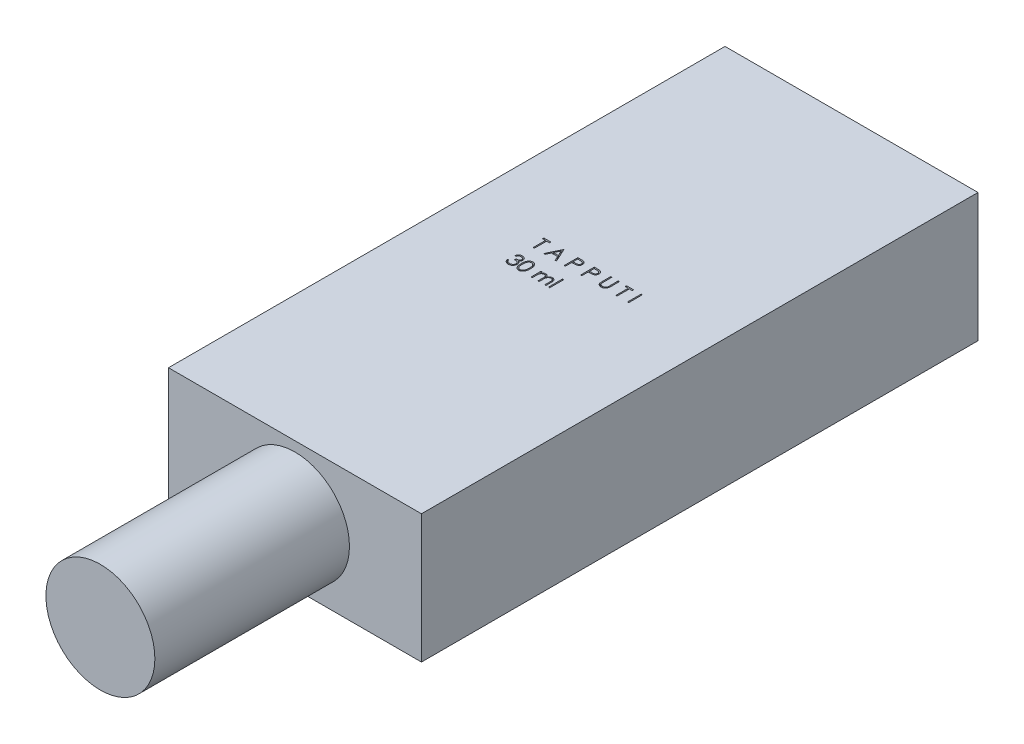
from build123d import *

# Parameters (mm, degrees)
SKETCH1_W           = 65
SKETCH1_H           = 143
BOSS_EXTRUDE1_DEPTH = 33
SKETCH2_W           = 0.314102564
SKETCH2_H           = 3.5
SKETCH2_H_2         = 3.58974359
CUT_EXTRUDE1_DEPTH  = 10
SKETCH4_R           = 14
BOSS_EXTRUDE2_DEPTH = 50


with BuildPart() as part:
    # Sketch1 → Boss-Extrude1 (new body)
    with BuildSketch(Plane(origin=(0, 0, 0), x_dir=(1, 0, 0), z_dir=(0, 1, 0))):
        Rectangle(SKETCH1_W, SKETCH1_H)
    extrude(amount=-BOSS_EXTRUDE1_DEPTH)

    # Sketch2 → Cut-Extrude1 (cut)
    with BuildSketch(Plane(origin=(0, 0, 0), x_dir=(1, 0, 0), z_dir=(0, 1, 0))):
        Polygon((-13.158043285, 5.236726447), (-13.158043285, 5.595700806), (-11.318299695, 5.595700806), (-11.318299695, 5.236726447), (-12.081120208, 5.236726447), (-12.081120208, 2.095700806), (-12.395222772, 2.095700806), (-12.395222772, 5.236726447), align=None)
        Polygon((-7.997786875, 5.595700806), (-6.382402259, 2.095700806), (-6.723848574, 2.095700806), (-7.241276458, 3.217495678), (-8.82791508, 3.217495678), (-9.360066522, 2.095700806), (-9.70291508, 2.095700806), (-8.04265867, 5.595700806), align=None)
        Polygon((-8.023728381, 4.9135093), (-8.657542484, 3.576470037), (-7.406741202, 3.576470037), align=None, mode=Mode.SUBTRACT)
        with BuildLine():
            Line((-4.408043285, 5.595700806), (-3.721645048, 5.595700806))
            add(Edge.make_bspline(
                [(-3.721645048, 5.595700806), (-3.674434142, 5.59564891), (-3.583975949, 5.595549475), (-3.454260893, 5.592534729), (-3.336451162, 5.588508037), (-3.230800781, 5.582926143), (-3.136984683, 5.576329553), (-3.055427383, 5.567077514), (-2.985487827, 5.557417218), (-2.943581377, 5.547595812), (-2.924469567, 5.543116672)],
                knots=[0, 0, 0, 0, 0.000141628, 0.000271366, 0.00038923, 0.000495248, 0.00058876, 0.000671296, 0.000741499, 0.00080036, 0.00080036, 0.00080036, 0.00080036], degree=3))
            add(Edge.make_bspline(
                [(-2.924469567, 5.543116672), (-2.900276033, 5.536494722), (-2.852459056, 5.52340686), (-2.783558013, 5.497193137), (-2.718004168, 5.466110972), (-2.655572609, 5.430687032), (-2.597030526, 5.389401468), (-2.541504485, 5.34392785), (-2.489484505, 5.293216281), (-2.441263113, 5.237835541), (-2.396978315, 5.178715331), (-2.358848633, 5.114973102), (-2.326921406, 5.047681798), (-2.299538134, 4.976888227), (-2.27982968, 4.901997903), (-2.26498278, 4.823531191), (-2.255559152, 4.741496501), (-2.25465659, 4.685436633), (-2.254197131, 4.656898723)],
                knots=[0, 0, 0, 0, 7.5216e-05, 0.00014866, 0.000220794, 0.000292713, 0.000363707, 0.000435434, 0.000507823, 0.000581364, 0.000655543, 0.000729131, 0.000803767, 0.000878771, 0.000956497, 0.001035702, 0.001118238, 0.001203821, 0.001203821, 0.001203821, 0.001203821], degree=3))
            add(Edge.make_bspline(
                [(-2.254197131, 4.656898723), (-2.254618556, 4.628120946), (-2.255443102, 4.571815282), (-2.265339387, 4.489442494), (-2.278669579, 4.410724104), (-2.299166631, 4.335834653), (-2.326012304, 4.265218883), (-2.357504357, 4.197797651), (-2.395487887, 4.134717979), (-2.439132717, 4.075750862), (-2.487684312, 4.020840949), (-2.54093725, 3.970386155), (-2.598676542, 3.924681816), (-2.66071869, 3.883625473), (-2.727668539, 3.848169193), (-2.798510693, 3.816411888), (-2.873860909, 3.789740828), (-2.926003423, 3.775710766), (-2.952514439, 3.768577409)],
                knots=[0, 0, 0, 0, 8.6284e-05, 0.00016882, 0.000248587, 0.000325638, 0.000401297, 0.000474998, 0.000548586, 0.000621785, 0.0006948, 0.0007682, 0.000841564, 0.000915458, 0.000991056, 0.00106858, 0.00114819, 0.001230532, 0.001230532, 0.001230532, 0.001230532], degree=3))
            add(Edge.make_bspline(
                [(-2.952514439, 3.768577409), (-2.974441773, 3.763914428), (-3.0224968, 3.753695234), (-3.101639522, 3.742286777), (-3.193784908, 3.732549176), (-3.298807188, 3.725248039), (-3.416612093, 3.71899767), (-3.547263351, 3.714029576), (-3.691017428, 3.711299722), (-3.791288672, 3.71115893), (-3.84364024, 3.711085422)],
                knots=[0, 0, 0, 0, 6.7238e-05, 0.000147357, 0.000239727, 0.000345177, 0.000463135, 0.000593636, 0.000737393, 0.000894446, 0.000894446, 0.000894446, 0.000894446], degree=3))
            Line((-3.84364024, 3.711085422), (-4.093940721, 3.711085422))
            Line((-4.093940721, 3.711085422), (-4.093940721, 2.095700806))
            Line((-4.093940721, 2.095700806), (-4.408043285, 2.095700806))
            Line((-4.408043285, 2.095700806), (-4.408043285, 5.595700806))
        make_face()
        with BuildLine():
            Line((-4.093940721, 5.236726447), (-4.093940721, 4.070059781))
            Line((-4.093940721, 4.070059781), (-3.481160272, 4.062347441))
            add(Edge.make_bspline(
                [(-3.481160272, 4.062347441), (-3.451240346, 4.062331977), (-3.393480546, 4.062302125), (-3.310044323, 4.066287349), (-3.232635036, 4.070887881), (-3.161490461, 4.077623805), (-3.096578526, 4.087145062), (-3.037790997, 4.0967568), (-2.985583714, 4.110662163), (-2.924484513, 4.129385232), (-2.856401165, 4.161317848), (-2.782333617, 4.207667738), (-2.71956303, 4.266748446), (-2.665244733, 4.333176277), (-2.622138856, 4.407075407), (-2.590582863, 4.486144343), (-2.572041706, 4.569572193), (-2.569555512, 4.626660332), (-2.568299695, 4.655496479)],
                knots=[0, 0, 0, 0, 8.9746e-05, 0.000173253, 0.000250533, 0.00032239, 0.000387534, 0.00044736, 0.000500926, 0.000549486, 0.000638903, 0.000725641, 0.000810488, 0.000896226, 0.000982324, 0.00106604, 0.001150757, 0.001237226, 0.001237226, 0.001237226, 0.001237226], degree=3))
            add(Edge.make_bspline(
                [(-2.568299695, 4.655496479), (-2.569562342, 4.683634993), (-2.572072327, 4.739570875), (-2.59072819, 4.821549636), (-2.622077504, 4.89978534), (-2.665534098, 4.972758425), (-2.718275228, 5.038947229), (-2.779574571, 5.096444356), (-2.849287833, 5.142666059), (-2.914136064, 5.172499341), (-2.97173725, 5.190714616), (-3.02176921, 5.203459457), (-3.078259884, 5.213635063), (-3.141227664, 5.221874566), (-3.210184498, 5.228928027), (-3.285722812, 5.233714004), (-3.367556456, 5.23651546), (-3.424367027, 5.236654416), (-3.453816522, 5.236726447)],
                knots=[0, 0, 0, 0, 8.4371e-05, 0.000167719, 0.000250783, 0.000336277, 0.000421575, 0.000503926, 0.000587348, 0.000671427, 0.000717102, 0.000768457, 0.000826213, 0.000889178, 0.000958942, 0.001034123, 0.001116202, 0.001204546, 0.001204546, 0.001204546, 0.001204546], degree=3))
            Line((-3.453816522, 5.236726447), (-4.093940721, 5.236726447))
        make_face(mode=Mode.SUBTRACT)
        with BuildLine():
            Line((-0.190094567, 5.595700806), (0.49630367, 5.595700806))
            add(Edge.make_bspline(
                [(0.49630367, 5.595700806), (0.543514576, 5.59564891), (0.633972769, 5.595549475), (0.763687825, 5.592534729), (0.881497556, 5.588508037), (0.987147937, 5.582926143), (1.080964035, 5.576329553), (1.162521335, 5.567077514), (1.232460891, 5.557417218), (1.274367341, 5.547595812), (1.293479151, 5.543116672)],
                knots=[0, 0, 0, 0, 0.000141628, 0.000271366, 0.00038923, 0.000495248, 0.00058876, 0.000671296, 0.000741499, 0.00080036, 0.00080036, 0.00080036, 0.00080036], degree=3))
            add(Edge.make_bspline(
                [(1.293479151, 5.543116672), (1.317672685, 5.536494722), (1.365489662, 5.52340686), (1.434390705, 5.497193137), (1.49994455, 5.466110972), (1.562376109, 5.430687032), (1.620918192, 5.389401468), (1.676444233, 5.34392785), (1.728464213, 5.293216281), (1.776685605, 5.237835541), (1.820970403, 5.178715331), (1.859100085, 5.114973102), (1.891027312, 5.047681798), (1.918410584, 4.976888227), (1.938119038, 4.901997903), (1.952965938, 4.823531191), (1.962389566, 4.741496501), (1.963292127, 4.685436633), (1.963751587, 4.656898723)],
                knots=[0, 0, 0, 0, 7.5216e-05, 0.00014866, 0.000220794, 0.000292713, 0.000363707, 0.000435434, 0.000507823, 0.000581364, 0.000655543, 0.000729131, 0.000803767, 0.000878771, 0.000956497, 0.001035702, 0.001118238, 0.001203821, 0.001203821, 0.001203821, 0.001203821], degree=3))
            add(Edge.make_bspline(
                [(1.963751587, 4.656898723), (1.963330162, 4.628120946), (1.962505616, 4.571815282), (1.952609331, 4.489442494), (1.939279139, 4.410724104), (1.918782087, 4.335834653), (1.891936414, 4.265218883), (1.860444361, 4.197797651), (1.82246083, 4.134717979), (1.778816001, 4.075750862), (1.730264406, 4.020840949), (1.677011468, 3.970386155), (1.619272176, 3.924681816), (1.557230028, 3.883625473), (1.490280179, 3.848169193), (1.419438025, 3.816411888), (1.344087809, 3.789740828), (1.291945295, 3.775710766), (1.265434279, 3.768577409)],
                knots=[0, 0, 0, 0, 8.6284e-05, 0.00016882, 0.000248587, 0.000325638, 0.000401297, 0.000474998, 0.000548586, 0.000621785, 0.0006948, 0.0007682, 0.000841564, 0.000915458, 0.000991056, 0.00106858, 0.00114819, 0.001230532, 0.001230532, 0.001230532, 0.001230532], degree=3))
            add(Edge.make_bspline(
                [(1.265434279, 3.768577409), (1.243506945, 3.763914428), (1.195451918, 3.753695234), (1.116309196, 3.742286777), (1.02416381, 3.732549176), (0.91914153, 3.725248039), (0.801336625, 3.71899767), (0.670685367, 3.714029576), (0.52693129, 3.711299722), (0.426660046, 3.71115893), (0.374308478, 3.711085422)],
                knots=[0, 0, 0, 0, 6.7238e-05, 0.000147357, 0.000239727, 0.000345177, 0.000463135, 0.000593636, 0.000737393, 0.000894446, 0.000894446, 0.000894446, 0.000894446], degree=3))
            Line((0.374308478, 3.711085422), (0.124007997, 3.711085422))
            Line((0.124007997, 3.711085422), (0.124007997, 2.095700806))
            Line((0.124007997, 2.095700806), (-0.190094567, 2.095700806))
            Line((-0.190094567, 2.095700806), (-0.190094567, 5.595700806))
        make_face()
        with BuildLine():
            Line((0.124007997, 5.236726447), (0.124007997, 4.070059781))
            Line((0.124007997, 4.070059781), (0.736788446, 4.062347441))
            add(Edge.make_bspline(
                [(0.736788446, 4.062347441), (0.766708372, 4.062331977), (0.824468171, 4.062302125), (0.907904395, 4.066287349), (0.985313682, 4.070887881), (1.056458257, 4.077623805), (1.121370192, 4.087145062), (1.180157721, 4.0967568), (1.232365004, 4.110662163), (1.293464205, 4.129385232), (1.361547553, 4.161317848), (1.435615101, 4.207667738), (1.498385688, 4.266748446), (1.552703984, 4.333176277), (1.595809862, 4.407075407), (1.627365855, 4.486144343), (1.645907012, 4.569572193), (1.648393206, 4.626660332), (1.649649023, 4.655496479)],
                knots=[0, 0, 0, 0, 8.9746e-05, 0.000173253, 0.000250533, 0.00032239, 0.000387534, 0.00044736, 0.000500926, 0.000549486, 0.000638903, 0.000725641, 0.000810488, 0.000896226, 0.000982324, 0.00106604, 0.001150757, 0.001237226, 0.001237226, 0.001237226, 0.001237226], degree=3))
            add(Edge.make_bspline(
                [(1.649649023, 4.655496479), (1.648386376, 4.683634993), (1.645876391, 4.739570875), (1.627220528, 4.821549636), (1.595871214, 4.89978534), (1.55241462, 4.972758425), (1.49967349, 5.038947229), (1.438374147, 5.096444356), (1.368660885, 5.142666059), (1.303812654, 5.172499341), (1.246211468, 5.190714616), (1.196179508, 5.203459457), (1.139688834, 5.213635063), (1.076721054, 5.221874566), (1.00776422, 5.228928027), (0.932225906, 5.233714004), (0.850392262, 5.23651546), (0.793581691, 5.236654416), (0.764132196, 5.236726447)],
                knots=[0, 0, 0, 0, 8.4371e-05, 0.000167719, 0.000250783, 0.000336277, 0.000421575, 0.000503926, 0.000587348, 0.000671427, 0.000717102, 0.000768457, 0.000826213, 0.000889178, 0.000958942, 0.001034123, 0.001116202, 0.001204546, 0.001204546, 0.001204546, 0.001204546], degree=3))
            Line((0.764132196, 5.236726447), (0.124007997, 5.236726447))
        make_face(mode=Mode.SUBTRACT)
        with BuildLine():
            Line((4.027854151, 5.595700806), (4.341956715, 5.595700806))
            Line((4.341956715, 5.595700806), (4.341956715, 3.498645518))
            add(Edge.make_bspline(
                [(4.341956715, 3.498645518), (4.341909971, 3.468964782), (4.341821266, 3.412640471), (4.34241378, 3.332472171), (4.344073149, 3.261199712), (4.345119308, 3.198548364), (4.347446642, 3.144805617), (4.349344689, 3.099680306), (4.351785245, 3.063386103), (4.354718363, 3.042205177), (4.355979151, 3.033100646)],
                knots=[0, 0, 0, 0, 8.9042e-05, 0.000168973, 0.000240502, 0.000302917, 0.000356945, 0.000401866, 0.000438432, 0.000465999, 0.000465999, 0.000465999, 0.000465999], degree=3))
            add(Edge.make_bspline(
                [(4.355979151, 3.033100646), (4.36115661, 3.000253883), (4.371219796, 2.936411154), (4.396866174, 2.845502872), (4.432683675, 2.763571413), (4.475126717, 2.688060122), (4.531059329, 2.621070762), (4.598062864, 2.55935911), (4.679240633, 2.505387305), (4.769501238, 2.456036493), (4.866786476, 2.416371411), (4.966197742, 2.386378046), (5.066240721, 2.368099147), (5.133216886, 2.365982608), (5.166475946, 2.364931576)],
                knots=[0, 0, 0, 0, 9.971e-05, 0.000193801, 0.000282365, 0.000367504, 0.000452699, 0.000543015, 0.000639862, 0.000744331, 0.000851226, 0.000954377, 0.001055468, 0.001155185, 0.001155185, 0.001155185, 0.001155185], degree=3))
            add(Edge.make_bspline(
                [(5.166475946, 2.364931576), (5.195029686, 2.366005426), (5.251972248, 2.368146924), (5.336578679, 2.381408355), (5.418978787, 2.405308921), (5.499579467, 2.436148679), (5.575130452, 2.47689627), (5.645673894, 2.52396711), (5.708637828, 2.579177986), (5.766095826, 2.64027833), (5.816130762, 2.70921813), (5.859501903, 2.784496268), (5.895027833, 2.867245615), (5.912571358, 2.925400038), (5.921584119, 2.955276127)],
                knots=[0, 0, 0, 0, 8.5678e-05, 0.00017086, 0.000256092, 0.000342674, 0.000429242, 0.000513055, 0.000596556, 0.000679898, 0.000764179, 0.00085149, 0.000940054, 0.001033621, 0.001033621, 0.001033621, 0.001033621], degree=3))
            add(Edge.make_bspline(
                [(5.921584119, 2.955276127), (5.924584244, 2.967624701), (5.931269732, 2.995142301), (5.937516777, 3.041663592), (5.944023303, 3.096552956), (5.948537873, 3.160204769), (5.952939093, 3.232405741), (5.955572166, 3.313531999), (5.956789199, 3.40328896), (5.957151879, 3.465926121), (5.95734133, 3.498645518)],
                knots=[0, 0, 0, 0, 3.81e-05, 8.4902e-05, 0.000140649, 0.000203941, 0.000276279, 0.000357657, 0.000447412, 0.000545571, 0.000545571, 0.000545571, 0.000545571], degree=3))
            Line((5.95734133, 3.498645518), (5.95734133, 5.595700806))
            Line((5.95734133, 5.595700806), (6.271443894, 5.595700806))
            Line((6.271443894, 5.595700806), (6.271443894, 3.481818595))
            add(Edge.make_bspline(
                [(6.271443894, 3.481818595), (6.271189774, 3.443720216), (6.270693843, 3.369368913), (6.266393266, 3.260417554), (6.259536266, 3.157064573), (6.249848178, 3.059296076), (6.237011175, 2.967461917), (6.222735955, 2.880757149), (6.204556422, 2.799804156), (6.18332302, 2.723971738), (6.159049472, 2.651786225), (6.127608324, 2.58327761), (6.092183824, 2.516363211), (6.050169171, 2.452055102), (6.002957789, 2.390068549), (5.949506108, 2.330779474), (5.891581947, 2.273240427), (5.828222387, 2.218927361), (5.760471862, 2.169118684), (5.688531904, 2.125320913), (5.612955135, 2.088297296), (5.533938009, 2.057821371), (5.451446806, 2.034906772), (5.365479446, 2.017831616), (5.275840253, 2.008129319), (5.214875596, 2.006687389), (5.184003991, 2.005957217)],
                knots=[0, 0, 0, 0, 0.000114291, 0.000223047, 0.000327049, 0.000424998, 0.000517708, 0.000605194, 0.000688542, 0.000766455, 0.0008414, 0.000916717, 0.000992315, 0.001068354, 0.001146882, 0.001225836, 0.001307639, 0.001391671, 0.001475952, 0.001559641, 0.001643989, 0.001728103, 0.001813335, 0.001900511, 0.00199079, 0.002083404, 0.002083404, 0.002083404, 0.002083404], degree=3))
            add(Edge.make_bspline(
                [(5.184003991, 2.005957217), (5.150334888, 2.006741982), (5.084276229, 2.008281689), (4.986938162, 2.017104439), (4.893623966, 2.033722833), (4.803348088, 2.054882777), (4.717339591, 2.084066514), (4.634446147, 2.118164639), (4.556087466, 2.160041899), (4.480992337, 2.206635292), (4.411167581, 2.25905993), (4.347070178, 2.316200104), (4.288594307, 2.377140482), (4.236725611, 2.442540847), (4.190604726, 2.511892554), (4.150874513, 2.585391794), (4.116761269, 2.66301011), (4.099154702, 2.716963311), (4.090253991, 2.744238467)],
                knots=[0, 0, 0, 0, 0.000101022, 0.000198206, 0.000292839, 0.000385177, 0.00047608, 0.000565014, 0.000653769, 0.000742283, 0.000829923, 0.000915339, 0.000999643, 0.001082971, 0.00116542, 0.001249186, 0.001333332, 0.001419362, 0.001419362, 0.001419362, 0.001419362], degree=3))
            add(Edge.make_bspline(
                [(4.090253991, 2.744238467), (4.085076832, 2.762871041), (4.073847461, 2.80328551), (4.061822163, 2.870171999), (4.051713082, 2.947186916), (4.042207524, 3.034335535), (4.036598566, 3.131685401), (4.031681127, 3.239194317), (4.027819508, 3.356992279), (4.02784228, 3.439046794), (4.027854151, 3.481818595)],
                knots=[0, 0, 0, 0, 5.799e-05, 0.000125782, 0.000203619, 0.000291034, 0.000388694, 0.000496078, 0.000613919, 0.000742226, 0.000742226, 0.000742226, 0.000742226], degree=3))
            Line((4.027854151, 3.481818595), (4.027854151, 5.595700806))
        make_face()
        Polygon((8.111187484, 5.236726447), (8.111187484, 5.595700806), (9.950931074, 5.595700806), (9.950931074, 5.236726447), (9.188110561, 5.236726447), (9.188110561, 2.095700806), (8.874007997, 2.095700806), (8.874007997, 5.236726447), align=None)
        with Locations((11.992597741, 3.845700806)):
            Rectangle(SKETCH2_W, SKETCH2_H)
        with BuildLine():
            Line((-12.619581747, -2.045324835), (-12.933684311, -2.045324835))
            add(Edge.make_bspline(
                [(-12.933684311, -2.045324835), (-12.92517476, -2.010092351), (-12.908539284, -1.941215726), (-12.873841711, -1.842808465), (-12.836042456, -1.749684944), (-12.790653351, -1.66358887), (-12.741144597, -1.582789968), (-12.684421875, -1.509120843), (-12.623102153, -1.440707878), (-12.555277204, -1.37999464), (-12.484148542, -1.325016911), (-12.408713922, -1.278141854), (-12.330491029, -1.237817701), (-12.248937896, -1.204597469), (-12.163811724, -1.179571945), (-12.075882101, -1.16141514), (-11.9849186, -1.149624025), (-11.92317101, -1.148473262), (-11.891817324, -1.147888937)],
                knots=[0, 0, 0, 0, 0.000108665, 0.000212431, 0.000312691, 0.000409905, 0.000504067, 0.000596618, 0.000688443, 0.000779278, 0.000869306, 0.00095782, 0.001045306, 0.001133058, 0.001221569, 0.001311085, 0.001402223, 0.001496238, 0.001496238, 0.001496238, 0.001496238], degree=3))
            add(Edge.make_bspline(
                [(-11.891817324, -1.147888937), (-11.846134581, -1.149268167), (-11.755765571, -1.151996543), (-11.623002524, -1.176910979), (-11.494975704, -1.216336112), (-11.373086457, -1.270809839), (-11.259868024, -1.337997152), (-11.159131837, -1.417961889), (-11.072243326, -1.50916119), (-10.999348949, -1.609893755), (-10.94227395, -1.717549264), (-10.900187576, -1.828349421), (-10.874565895, -1.942031393), (-10.871245338, -2.018788672), (-10.869581747, -2.057243905)],
                knots=[0, 0, 0, 0, 0.000136936, 0.000270885, 0.000403723, 0.000538055, 0.000670441, 0.000797677, 0.000922646, 0.001047185, 0.00116951, 0.001287103, 0.001401935, 0.001517226, 0.001517226, 0.001517226, 0.001517226], degree=3))
            add(Edge.make_bspline(
                [(-10.869581747, -2.057243905), (-10.870745338, -2.0942507), (-10.873022305, -2.166667254), (-10.89235601, -2.272388752), (-10.924892273, -2.372030352), (-10.969962036, -2.466011514), (-11.028303586, -2.553736354), (-11.098976283, -2.635402245), (-11.182478945, -2.711371403), (-11.245757883, -2.754890876), (-11.278335753, -2.777295989)],
                knots=[0, 0, 0, 0, 0.000110957, 0.000217125, 0.000321111, 0.000424595, 0.000528824, 0.000636204, 0.000747885, 0.000866393, 0.000866393, 0.000866393, 0.000866393], degree=3))
            add(Edge.make_bspline(
                [(-11.278335753, -2.777295989), (-11.241103998, -2.79527416), (-11.167337124, -2.830894118), (-11.066786595, -2.900749875), (-10.975508719, -2.981406223), (-10.924605, -3.044348875), (-10.899028862, -3.075973873)],
                knots=[0, 0, 0, 0, 0.000123863, 0.000245408, 0.000366052, 0.000487879, 0.000487879, 0.000487879, 0.000487879], degree=3))
            add(Edge.make_bspline(
                [(-10.899028862, -3.075973873), (-10.88218752, -3.099031625), (-10.848780624, -3.144769541), (-10.80754509, -3.218305967), (-10.770135976, -3.292657456), (-10.740985756, -3.369816863), (-10.718411889, -3.448889876), (-10.702275857, -3.530012272), (-10.692251716, -3.613250295), (-10.690816164, -3.669562775), (-10.690094567, -3.697868905)],
                knots=[0, 0, 0, 0, 8.5583e-05, 0.000169764, 0.000252544, 0.000335098, 0.000416766, 0.000498992, 0.000583001, 0.000667909, 0.000667909, 0.000667909, 0.000667909], degree=3))
            add(Edge.make_bspline(
                [(-10.690094567, -3.697868905), (-10.691889081, -3.746878626), (-10.695469663, -3.844667428), (-10.727473737, -3.98914215), (-10.777086978, -4.130367652), (-10.847543914, -4.265442491), (-10.933411422, -4.391822872), (-11.035568747, -4.504899181), (-11.152855155, -4.602097786), (-11.283660804, -4.683308014), (-11.425377932, -4.748225936), (-11.576953524, -4.793283379), (-11.736203578, -4.822629379), (-11.845410876, -4.825776247), (-11.900931907, -4.827376117)],
                knots=[0, 0, 0, 0, 0.000146863, 0.000293035, 0.000441833, 0.000594857, 0.000748684, 0.000899086, 0.001050437, 0.001204129, 0.001359752, 0.001516561, 0.001677477, 0.001843893, 0.001843893, 0.001843893, 0.001843893], degree=3))
            add(Edge.make_bspline(
                [(-11.900931907, -4.827376117), (-11.938351207, -4.826507903), (-12.011979912, -4.824799549), (-12.120223411, -4.813120948), (-12.22354511, -4.791790943), (-12.322084708, -4.763087638), (-12.415929744, -4.726695895), (-12.504793849, -4.681377197), (-12.589223743, -4.628065695), (-12.668422694, -4.566132108), (-12.742381262, -4.496850768), (-12.809133986, -4.418991758), (-12.869793779, -4.333994354), (-12.922736418, -4.240871298), (-12.97037337, -4.14082604), (-13.009554327, -4.032577542), (-13.044039896, -3.91709352), (-13.06007336, -3.83661578), (-13.068299695, -3.795324835)],
                knots=[0, 0, 0, 0, 0.000112258, 0.000220887, 0.000326076, 0.000428356, 0.000528479, 0.000627563, 0.000727152, 0.000827569, 0.00092875, 0.001030654, 0.001134734, 0.001241526, 0.001351611, 0.001466743, 0.00158655, 0.001712791, 0.001712791, 0.001712791, 0.001712791], degree=3))
            Line((-13.068299695, -3.795324835), (-12.754197131, -3.795324835))
            add(Edge.make_bspline(
                [(-12.754197131, -3.795324835), (-12.74601384, -3.822273848), (-12.730096627, -3.87469202), (-12.703002329, -3.950132325), (-12.672134057, -4.019290378), (-12.639019498, -4.0826735), (-12.604241052, -4.140905903), (-12.565326127, -4.192447772), (-12.525156982, -4.239562974), (-12.494877629, -4.266107586), (-12.480058509, -4.279098873)],
                knots=[0, 0, 0, 0, 8.4487e-05, 0.000164335, 0.000240293, 0.00031148, 0.000378817, 0.000443461, 0.000505064, 0.000564113, 0.000564113, 0.000564113, 0.000564113], degree=3))
            add(Edge.make_bspline(
                [(-12.480058509, -4.279098873), (-12.460461933, -4.294207207), (-12.42132927, -4.324377239), (-12.357561039, -4.362878867), (-12.290496153, -4.396239893), (-12.218681479, -4.421723588), (-12.143666708, -4.443301249), (-12.064239343, -4.457421768), (-11.981100126, -4.46710994), (-11.924332362, -4.467964871), (-11.895322932, -4.468401758)],
                knots=[0, 0, 0, 0, 7.418e-05, 0.000148131, 0.000223072, 0.000298488, 0.0003764, 0.000456984, 0.000540217, 0.000627201, 0.000627201, 0.000627201, 0.000627201], degree=3))
            add(Edge.make_bspline(
                [(-11.895322932, -4.468401758), (-11.86256943, -4.467785853), (-11.798522783, -4.466581503), (-11.705067924, -4.455505796), (-11.616160476, -4.439375383), (-11.53278755, -4.4144624), (-11.453857043, -4.383681548), (-11.380475393, -4.345033143), (-11.311679287, -4.299688421), (-11.248349882, -4.248149263), (-11.191404374, -4.191727768), (-11.141264861, -4.132714697), (-11.098640199, -4.071358867), (-11.064256621, -4.007320746), (-11.037106071, -3.940865517), (-11.01862287, -3.871806688), (-11.005771355, -3.800709422), (-11.004724743, -3.752380453), (-11.004197131, -3.728017142)],
                knots=[0, 0, 0, 0, 9.822e-05, 0.00019206, 0.00028199, 0.000368957, 0.000452673, 0.000535779, 0.000617257, 0.000699492, 0.000780303, 0.000857417, 0.000931514, 0.001003978, 0.001075065, 0.001146335, 0.001218144, 0.001291145, 0.001291145, 0.001291145, 0.001291145], degree=3))
            add(Edge.make_bspline(
                [(-11.004197131, -3.728017142), (-11.005727433, -3.695405804), (-11.008780421, -3.630345395), (-11.032089001, -3.534627821), (-11.070427865, -3.442404409), (-11.124100376, -3.355248618), (-11.189436105, -3.274472717), (-11.265801012, -3.202401234), (-11.35382924, -3.142931143), (-11.434849109, -3.101842487), (-11.506614266, -3.073805412), (-11.56802965, -3.055130447), (-11.636786253, -3.039316792), (-11.712052602, -3.02460452), (-11.794395819, -3.012083172), (-11.883726257, -3.001641356), (-11.980062018, -2.993286315), (-12.046753184, -2.98955522), (-12.081120208, -2.987632527)],
                knots=[0, 0, 0, 0, 9.7761e-05, 0.000195035, 0.000293731, 0.000396299, 0.00050098, 0.000604654, 0.000710058, 0.000818548, 0.000876487, 0.000941025, 0.001010919, 0.001088059, 0.001171055, 0.001260716, 0.001357836, 0.001461094, 0.001461094, 0.001461094, 0.001461094], degree=3))
            Line((-12.081120208, -2.987632527), (-12.081120208, -2.628658168))
            add(Edge.make_bspline(
                [(-12.081120208, -2.628658168), (-12.037819042, -2.627923364), (-11.953002696, -2.626484064), (-11.829108391, -2.609076054), (-11.710635079, -2.584995426), (-11.600208337, -2.548110234), (-11.499559624, -2.505269937), (-11.412240022, -2.455417727), (-11.339472874, -2.400002978), (-11.281611803, -2.338170369), (-11.238082574, -2.271855321), (-11.206255777, -2.202738663), (-11.18745545, -2.130214603), (-11.184945784, -2.080719935), (-11.183684311, -2.055841662)],
                knots=[0, 0, 0, 0, 0.0001298, 0.000254247, 0.000374709, 0.000491998, 0.000602842, 0.000702416, 0.000792872, 0.000876214, 0.000955164, 0.001029842, 0.001103644, 0.00117823, 0.00117823, 0.00117823, 0.00117823], degree=3))
            add(Edge.make_bspline(
                [(-11.183684311, -2.055841662), (-11.184098722, -2.037563916), (-11.184923173, -2.001201209), (-11.19532045, -1.948076141), (-11.210944491, -1.896575195), (-11.232424221, -1.846917385), (-11.261174419, -1.799447111), (-11.295580406, -1.753759662), (-11.336548506, -1.710115883), (-11.383493953, -1.669435563), (-11.433905758, -1.630666326), (-11.489155533, -1.597752689), (-11.547577408, -1.569607627), (-11.609236063, -1.546398125), (-11.674331593, -1.528938837), (-11.742558151, -1.516402995), (-11.814045834, -1.50856534), (-11.862817566, -1.507436925), (-11.887610593, -1.506863296)],
                knots=[0, 0, 0, 0, 5.4759e-05, 0.000108941, 0.000161726, 0.000216044, 0.000270754, 0.000327825, 0.00038735, 0.000449943, 0.000514025, 0.000577874, 0.000642472, 0.000708366, 0.000775209, 0.000844379, 0.000916308, 0.00099068, 0.00099068, 0.00099068, 0.00099068], degree=3))
            add(Edge.make_bspline(
                [(-11.887610593, -1.506863296), (-11.927462261, -1.508254658), (-12.005301837, -1.510972312), (-12.117516754, -1.534775325), (-12.221836088, -1.572753409), (-12.301574755, -1.618086428), (-12.360457329, -1.662836862), (-12.402534267, -1.701919248), (-12.443854777, -1.745352072), (-12.481700454, -1.795810447), (-12.519974431, -1.849877238), (-12.554818992, -1.910300919), (-12.588678685, -1.975505313), (-12.609081234, -2.021600948), (-12.619581747, -2.045324835)],
                knots=[0, 0, 0, 0, 0.00011944, 0.000233294, 0.000342435, 0.0004514, 0.000506931, 0.000563998, 0.000623523, 0.000686492, 0.000753006, 0.000822147, 0.000895524, 0.000973336, 0.000973336, 0.000973336, 0.000973336], degree=3))
        make_face()
        with BuildLine():
            add(Edge.make_bspline(
                [(-10.375992003, -2.989034771), (-10.375663985, -2.932937383), (-10.375026805, -2.823967399), (-10.367938384, -2.665182757), (-10.356163042, -2.516222468), (-10.340025669, -2.377079402), (-10.320387689, -2.247717637), (-10.294172202, -2.12848288), (-10.264359399, -2.018823273), (-10.229806953, -1.918381225), (-10.190819164, -1.825803522), (-10.148384904, -1.73937832), (-10.100820109, -1.659236388), (-10.050843196, -1.584098598), (-9.996431125, -1.515194903), (-9.939132334, -1.45155224), (-9.876710458, -1.39464149), (-9.81128745, -1.342795188), (-9.742270985, -1.297345716), (-9.671628319, -1.257312977), (-9.598873213, -1.22311311), (-9.52380703, -1.196222674), (-9.447104473, -1.174011827), (-9.368497406, -1.15882288), (-9.287856042, -1.149265971), (-9.233424607, -1.148352303), (-9.205819727, -1.147888937)],
                knots=[0, 0, 0, 0, 0.000168282, 0.000326891, 0.000476705, 0.00061646, 0.000747059, 0.00086904, 0.000982494, 0.001087814, 0.001187428, 0.001283689, 0.001376399, 0.001466822, 0.001554203, 0.001639568, 0.001723424, 0.001807301, 0.001889751, 0.001971063, 0.002050735, 0.002130583, 0.002210036, 0.002290062, 0.002370508, 0.002453288, 0.002453288, 0.002453288, 0.002453288], degree=3))
            add(Edge.make_bspline(
                [(-9.205819727, -1.147888937), (-9.177984249, -1.148376752), (-9.12262824, -1.149346863), (-9.040787865, -1.158670806), (-8.960838183, -1.174141929), (-8.883120044, -1.196062904), (-8.806995058, -1.22325858), (-8.73305865, -1.257345697), (-8.660851569, -1.297024565), (-8.591521281, -1.343648442), (-8.524306666, -1.395630718), (-8.460858703, -1.454393387), (-8.401171617, -1.519343106), (-8.344496311, -1.58978497), (-8.292440714, -1.667070055), (-8.242867282, -1.749854165), (-8.198495246, -1.83958503), (-8.155760571, -1.934765497), (-8.118873584, -2.038029156), (-8.085607339, -2.148793917), (-8.05872837, -2.268368104), (-8.036339098, -2.396124349), (-8.018994202, -2.532531832), (-8.00636156, -2.677298148), (-7.999688475, -2.830518538), (-7.998431774, -2.935276387), (-7.997786875, -2.989034771)],
                knots=[0, 0, 0, 0, 8.3481e-05, 0.000166017, 0.000246731, 0.000327534, 0.000408041, 0.000488986, 0.000571522, 0.000654944, 0.000739373, 0.000826202, 0.000914021, 0.001003809, 0.001097153, 0.001193347, 0.001293057, 0.001397277, 0.001506176, 0.001621751, 0.001744038, 0.001873599, 0.002010742, 0.002156422, 0.002309427, 0.002470709, 0.002470709, 0.002470709, 0.002470709], degree=3))
            add(Edge.make_bspline(
                [(-7.997786875, -2.989034771), (-7.998438459, -3.042558679), (-7.999708045, -3.14684783), (-8.006286752, -3.299378806), (-8.019245383, -3.443376849), (-8.035455372, -3.579187311), (-8.057906334, -3.70624493), (-8.085511501, -3.824989379), (-8.116161824, -3.93593345), (-8.153996618, -4.038168262), (-8.195407328, -4.133119985), (-8.240462524, -4.221787133), (-8.28873235, -4.304953426), (-8.341321095, -4.381953173), (-8.397374508, -4.45333183), (-8.458092297, -4.517829453), (-8.521762882, -4.577000125), (-8.589175298, -4.629651752), (-8.659586849, -4.675736557), (-8.731545926, -4.716950407), (-8.80632931, -4.750183102), (-8.882242262, -4.778718143), (-8.960370629, -4.800518595), (-9.040617019, -4.81559245), (-9.122573255, -4.826164299), (-9.17797482, -4.826970779), (-9.205819727, -4.827376117)],
                knots=[0, 0, 0, 0, 0.000160581, 0.000312886, 0.000457868, 0.000594226, 0.000723097, 0.000844701, 0.000959884, 0.001068125, 0.001171421, 0.001270505, 0.001366343, 0.001459687, 0.001550023, 0.00163832, 0.001725149, 0.001810562, 0.001894568, 0.001977446, 0.00205903, 0.002139777, 0.00222058, 0.002301983, 0.002384599, 0.00246808, 0.00246808, 0.00246808, 0.00246808], degree=3))
            add(Edge.make_bspline(
                [(-9.205819727, -4.827376117), (-9.233423841, -4.826909761), (-9.287853766, -4.825990199), (-9.368506192, -4.816476468), (-9.446788635, -4.801180965), (-9.523087389, -4.779764361), (-9.597793904, -4.753549524), (-9.669890191, -4.719395841), (-9.740177874, -4.680061772), (-9.80846943, -4.63526635), (-9.873481592, -4.583944667), (-9.935580197, -4.527180378), (-9.993205216, -4.463556967), (-10.046839312, -4.394079044), (-10.0978134, -4.319385802), (-10.144702773, -4.238457429), (-10.188073627, -4.151614818), (-10.227717118, -4.058296907), (-10.262865781, -3.95714198), (-10.293913489, -3.846992801), (-10.318427647, -3.726877165), (-10.339410602, -3.597759798), (-10.356334985, -3.459085868), (-10.367889311, -3.310780089), (-10.375030626, -3.15293488), (-10.375665696, -3.044665106), (-10.375992003, -2.989034771)],
                knots=[0, 0, 0, 0, 8.278e-05, 0.000163226, 0.000243252, 0.00032184, 0.00040079, 0.000480463, 0.00056082, 0.000642298, 0.000725191, 0.000809047, 0.000894412, 0.000982346, 0.001072188, 0.001165503, 0.001262704, 0.001363236, 0.001469448, 0.001583766, 0.001706286, 0.001836995, 0.001976138, 0.002125253, 0.002283161, 0.002450041, 0.002450041, 0.002450041, 0.002450041], degree=3))
        make_face()
        with BuildLine():
            add(Edge.make_bspline(
                [(-10.061889439, -2.987632527), (-10.061769992, -3.034381226), (-10.061538169, -3.125111271), (-10.055481968, -3.256954532), (-10.047231736, -3.37992486), (-10.036590439, -3.494178397), (-10.02078749, -3.599328409), (-10.003080702, -3.696098092), (-9.981532613, -3.78397533), (-9.956037595, -3.86356314), (-9.926998498, -3.936212209), (-9.895292634, -4.003813424), (-9.861231911, -4.06716536), (-9.823112761, -4.125698969), (-9.781597698, -4.179605133), (-9.737624439, -4.229837965), (-9.689551854, -4.274634946), (-9.623048112, -4.328361801), (-9.535251637, -4.383880935), (-9.424631182, -4.432227025), (-9.310962731, -4.462609481), (-9.233811481, -4.466473237), (-9.1953029, -4.468401758)],
                knots=[0, 0, 0, 0, 0.000140231, 0.000272162, 0.000395845, 0.00050998, 0.000616273, 0.00071473, 0.000805025, 0.000887508, 0.000965234, 0.00103957, 0.001111417, 0.001180842, 0.001248855, 0.001315406, 0.001380877, 0.0014457, 0.001571746, 0.00169106, 0.001806864, 0.001922266, 0.001922266, 0.001922266, 0.001922266], degree=3))
            add(Edge.make_bspline(
                [(-9.1953029, -4.468401758), (-9.156545229, -4.466803977), (-9.079109906, -4.463611714), (-8.96597611, -4.432812977), (-8.85614584, -4.386343437), (-8.7700739, -4.331395932), (-8.704591357, -4.279067602), (-8.657674366, -4.234452954), (-8.614612318, -4.184497087), (-8.573770243, -4.130597791), (-8.536311168, -4.071725307), (-8.50224803, -4.008162731), (-8.471164682, -3.939733554), (-8.453455636, -3.891963814), (-8.444401458, -3.86754038)],
                knots=[0, 0, 0, 0, 0.000116044, 0.000231848, 0.000349318, 0.000472837, 0.000536674, 0.000600645, 0.000666733, 0.000734322, 0.000803367, 0.000875831, 0.000950509, 0.001028633, 0.001028633, 0.001028633, 0.001028633], degree=3))
            add(Edge.make_bspline(
                [(-8.444401458, -3.86754038), (-8.43384969, -3.83631064), (-8.412425077, -3.772900876), (-8.384813302, -3.674537224), (-8.363067903, -3.57133446), (-8.343504537, -3.463909343), (-8.330151481, -3.351469642), (-8.319403668, -3.234363258), (-8.313072981, -3.112501896), (-8.31228823, -3.029706905), (-8.311889439, -2.987632527)],
                knots=[0, 0, 0, 0, 9.8886e-05, 0.00020078, 0.000306259, 0.000415188, 0.00052824, 0.000645799, 0.000767957, 0.000894177, 0.000894177, 0.000894177, 0.000894177], degree=3))
            add(Edge.make_bspline(
                [(-8.311889439, -2.987632527), (-8.312439628, -2.945564954), (-8.313515916, -2.86327179), (-8.317629904, -2.742753609), (-8.328253478, -2.628285848), (-8.340052597, -2.519375375), (-8.357449818, -2.416625073), (-8.376207625, -2.319174767), (-8.401408837, -2.228231743), (-8.428328612, -2.142372161), (-8.459139008, -2.062571506), (-8.493054742, -1.98845772), (-8.529276501, -1.919672995), (-8.568618741, -1.856406054), (-8.610614424, -1.798373511), (-8.656371973, -1.746738916), (-8.704076346, -1.699901948), (-8.770893532, -1.646439379), (-8.858367822, -1.591927684), (-8.967213469, -1.541761924), (-9.080484113, -1.512953631), (-9.157057568, -1.508891944), (-9.1953029, -1.506863296)],
                knots=[0, 0, 0, 0, 0.000126219, 0.000246912, 0.000361616, 0.00047102, 0.00057545, 0.000674176, 0.000768567, 0.000858368, 0.000944043, 0.001024988, 0.001102772, 0.001177091, 0.00124833, 0.001317386, 0.001383826, 0.001448649, 0.001573728, 0.001692043, 0.001806995, 0.001921698, 0.001921698, 0.001921698, 0.001921698], degree=3))
            add(Edge.make_bspline(
                [(-9.1953029, -1.506863296), (-9.234013493, -1.508894743), (-9.311505198, -1.512961337), (-9.425953153, -1.541654591), (-9.535657505, -1.591667557), (-9.622900479, -1.646619929), (-9.689764266, -1.69895824), (-9.736846959, -1.744344694), (-9.780993131, -1.793990949), (-9.821660831, -1.848392864), (-9.859750115, -1.906858231), (-9.894731127, -1.969846996), (-9.926248457, -2.03767836), (-9.955332993, -2.110294795), (-9.980905781, -2.18987574), (-10.001999744, -2.277644733), (-10.021486797, -2.374106625), (-10.035282066, -2.479826133), (-10.047545822, -2.594108287), (-10.05542717, -2.717385605), (-10.061558428, -2.849449985), (-10.061776892, -2.940649144), (-10.061889439, -2.987632527)],
                knots=[0, 0, 0, 0, 0.000116101, 0.000232413, 0.000351368, 0.000476447, 0.000540832, 0.000605795, 0.000672346, 0.000739935, 0.00080936, 0.000881545, 0.00095588, 0.001033607, 0.001116089, 0.001206384, 0.001304286, 0.001411174, 0.001526077, 0.001649061, 0.001781692, 0.001922624, 0.001922624, 0.001922624, 0.001922624], degree=3))
        make_face(mode=Mode.SUBTRACT)
        with BuildLine():
            Line((-6.11317149, -2.179940219), (-5.799068926, -2.179940219))
            Line((-5.799068926, -2.179940219), (-5.799068926, -2.624451437))
            add(Edge.make_bspline(
                [(-5.799068926, -2.624451437), (-5.770784976, -2.585563836), (-5.716590217, -2.511051462), (-5.627724564, -2.412861178), (-5.538948452, -2.329533024), (-5.47501507, -2.285790152), (-5.444301298, -2.264775956)],
                knots=[0, 0, 0, 0, 0.000144152, 0.000276209, 0.000396804, 0.000508302, 0.000508302, 0.000508302, 0.000508302], degree=3))
            add(Edge.make_bspline(
                [(-5.444301298, -2.264775956), (-5.402436636, -2.244770591), (-5.319438736, -2.205109378), (-5.188019511, -2.164875819), (-5.053544842, -2.140150718), (-4.962736628, -2.136769344), (-4.917057708, -2.135068424)],
                knots=[0, 0, 0, 0, 0.000139031, 0.000275633, 0.000410962, 0.000547939, 0.000547939, 0.000547939, 0.000547939], degree=3))
            add(Edge.make_bspline(
                [(-4.917057708, -2.135068424), (-4.886164712, -2.136113715), (-4.825029133, -2.138182289), (-4.734445042, -2.151642325), (-4.646586431, -2.174908498), (-4.561972401, -2.207315822), (-4.482251722, -2.246562509), (-4.409162524, -2.292612216), (-4.343538316, -2.344309292), (-4.285412265, -2.403988225), (-4.233143239, -2.473324823), (-4.185064393, -2.554189072), (-4.14063918, -2.648396733), (-4.116017872, -2.716763274), (-4.103055304, -2.752756726)],
                knots=[0, 0, 0, 0, 9.2678e-05, 0.000183405, 0.000274048, 0.000364807, 0.000454797, 0.00054019, 0.000623517, 0.000704829, 0.000789387, 0.000883415, 0.000986597, 0.001101318, 0.001101318, 0.001101318, 0.001101318], degree=3))
            add(Edge.make_bspline(
                [(-4.103055304, -2.752756726), (-4.089344053, -2.728032306), (-4.062362236, -2.679378121), (-4.017056599, -2.610519859), (-3.969588802, -2.546113067), (-3.919554309, -2.486106643), (-3.867129722, -2.430796913), (-3.812068322, -2.380001011), (-3.754683541, -2.333500797), (-3.674891301, -2.279177638), (-3.571078693, -2.221476456), (-3.440190579, -2.171448012), (-3.304040407, -2.140531884), (-3.211622709, -2.136901611), (-3.164954343, -2.135068424)],
                knots=[0, 0, 0, 0, 8.4789e-05, 0.000166854, 0.000247064, 0.000324714, 0.000401089, 0.000475513, 0.000549314, 0.000622436, 0.0007649, 0.000904487, 0.001041601, 0.001181469, 0.001181469, 0.001181469, 0.001181469], degree=3))
            add(Edge.make_bspline(
                [(-3.164954343, -2.135068424), (-3.12207288, -2.136685645), (-3.038149694, -2.139850704), (-2.915972428, -2.164704177), (-2.802030623, -2.207381824), (-2.696553547, -2.265615461), (-2.601393733, -2.338794644), (-2.518677424, -2.425863481), (-2.448907061, -2.526206104), (-2.403328421, -2.620598093), (-2.372413157, -2.703933426), (-2.353351922, -2.774939717), (-2.336512227, -2.85309127), (-2.322530982, -2.938481532), (-2.31231243, -3.03141214), (-2.304741714, -3.131731016), (-2.299617641, -3.239516128), (-2.299255569, -3.313881628), (-2.299068926, -3.35221586)],
                knots=[0, 0, 0, 0, 0.000128581, 0.000251645, 0.00037211, 0.000492305, 0.000611786, 0.000730807, 0.000851198, 0.000976936, 0.001044145, 0.001117629, 0.001197252, 0.00128393, 0.001377074, 0.001477631, 0.001585715, 0.001700707, 0.001700707, 0.001700707, 0.001700707], degree=3))
            Line((-2.299068926, -3.35221586), (-2.299068926, -4.737632527))
            Line((-2.299068926, -4.737632527), (-2.61317149, -4.737632527))
            Line((-2.61317149, -4.737632527), (-2.61317149, -3.350813617))
            add(Edge.make_bspline(
                [(-2.61317149, -3.350813617), (-2.613249373, -3.318093043), (-2.613399052, -3.255209076), (-2.616092684, -3.164956625), (-2.621167998, -3.082688267), (-2.627102637, -3.008516179), (-2.635346446, -2.942267391), (-2.645992378, -2.884074972), (-2.657270058, -2.833481161), (-2.676006049, -2.777395113), (-2.705953941, -2.715524903), (-2.751571421, -2.648801327), (-2.809041527, -2.590720527), (-2.875401683, -2.54030221), (-2.950950128, -2.499308569), (-3.034214851, -2.470032559), (-3.124678903, -2.451909681), (-3.187301691, -2.450103665), (-3.219641843, -2.449170989)],
                knots=[0, 0, 0, 0, 9.816e-05, 0.000188648, 0.000270826, 0.000345412, 0.000411852, 0.000470988, 0.000522857, 0.0005672, 0.000648106, 0.000728233, 0.000808554, 0.000892128, 0.000977461, 0.001065278, 0.001156029, 0.001252946, 0.001252946, 0.001252946, 0.001252946], degree=3))
            add(Edge.make_bspline(
                [(-3.219641843, -2.449170989), (-3.259311797, -2.450587146), (-3.337714708, -2.453386011), (-3.452160195, -2.481959884), (-3.562131211, -2.525040135), (-3.664346344, -2.587472592), (-3.758374135, -2.662280956), (-3.839273712, -2.751230552), (-3.906105898, -2.851860479), (-3.951359874, -2.945007181), (-3.979949175, -3.028676625), (-3.998826091, -3.101773997), (-4.013509483, -3.184855565), (-4.027280012, -3.277363055), (-4.03626774, -3.379933236), (-4.044436112, -3.492091637), (-4.048256975, -3.614175596), (-4.048791434, -3.698802285), (-4.049068926, -3.7427407)],
                knots=[0, 0, 0, 0, 0.000118788, 0.00023477, 0.000351815, 0.000471937, 0.000592603, 0.000711217, 0.000831002, 0.000953929, 0.001020668, 0.001096002, 0.00118016, 0.001273662, 0.001376495, 0.001488939, 0.001611007, 0.001742825, 0.001742825, 0.001742825, 0.001742825], degree=3))
            Line((-4.049068926, -3.7427407), (-4.049068926, -4.737632527))
            Line((-4.049068926, -4.737632527), (-4.36317149, -4.737632527))
            Line((-4.36317149, -4.737632527), (-4.36317149, -3.437051598))
            add(Edge.make_bspline(
                [(-4.36317149, -3.437051598), (-4.363250921, -3.400358279), (-4.363403738, -3.329764022), (-4.366080056, -3.228530346), (-4.371166677, -3.136449266), (-4.377047226, -3.053627802), (-4.385507404, -2.980216474), (-4.395117166, -2.915821716), (-4.406465777, -2.860604964), (-4.425255662, -2.80004158), (-4.45397013, -2.733320657), (-4.500158392, -2.662179635), (-4.557765972, -2.599911538), (-4.625336848, -2.546752789), (-4.70134253, -2.502811308), (-4.785325931, -2.471151556), (-4.876530844, -2.452727267), (-4.93940855, -2.45037877), (-4.971745208, -2.449170989)],
                knots=[0, 0, 0, 0, 0.000110078, 0.00021178, 0.000303758, 0.00038673, 0.000460827, 0.00052538, 0.000582037, 0.000629718, 0.00071543, 0.000799052, 0.000882908, 0.000968755, 0.001056067, 0.001145266, 0.001236843, 0.001333803, 0.001333803, 0.001333803, 0.001333803], degree=3))
            add(Edge.make_bspline(
                [(-4.971745208, -2.449170989), (-5.00976142, -2.450701449), (-5.085526379, -2.453751601), (-5.196828349, -2.481205875), (-5.304314032, -2.52420995), (-5.406268731, -2.583869769), (-5.499942879, -2.657768847), (-5.581951147, -2.744683743), (-5.650893672, -2.843532777), (-5.696625487, -2.935697293), (-5.726123961, -3.017270568), (-5.745719296, -3.086621516), (-5.762558922, -3.163621764), (-5.775072943, -3.248508875), (-5.787153359, -3.340729969), (-5.792983668, -3.440744459), (-5.79865523, -3.548466547), (-5.798927645, -3.622839092), (-5.799068926, -3.661410572)],
                knots=[0, 0, 0, 0, 0.000113893, 0.000226985, 0.000341817, 0.000460265, 0.000580056, 0.000698595, 0.000817435, 0.000940348, 0.001005999, 0.001077458, 0.001156396, 0.001242271, 0.001334801, 0.001435306, 0.00154269, 0.001658383, 0.001658383, 0.001658383, 0.001658383], degree=3))
            Line((-5.799068926, -3.661410572), (-5.799068926, -4.737632527))
            Line((-5.799068926, -4.737632527), (-6.11317149, -4.737632527))
            Line((-6.11317149, -4.737632527), (-6.11317149, -2.179940219))
        make_face()
        with Locations((-1.468940721, -2.942760732)):
            Rectangle(SKETCH2_W, SKETCH2_H_2)
    extrude(amount=-CUT_EXTRUDE1_DEPTH, mode=Mode.SUBTRACT)

    # Sketch4 → Boss-Extrude2 (add)
    with BuildSketch(Plane.XY.offset(71.5)):
        with Locations((0, -16.5)):
            Circle(SKETCH4_R)
    extrude(amount=BOSS_EXTRUDE2_DEPTH)


solid = part.part
